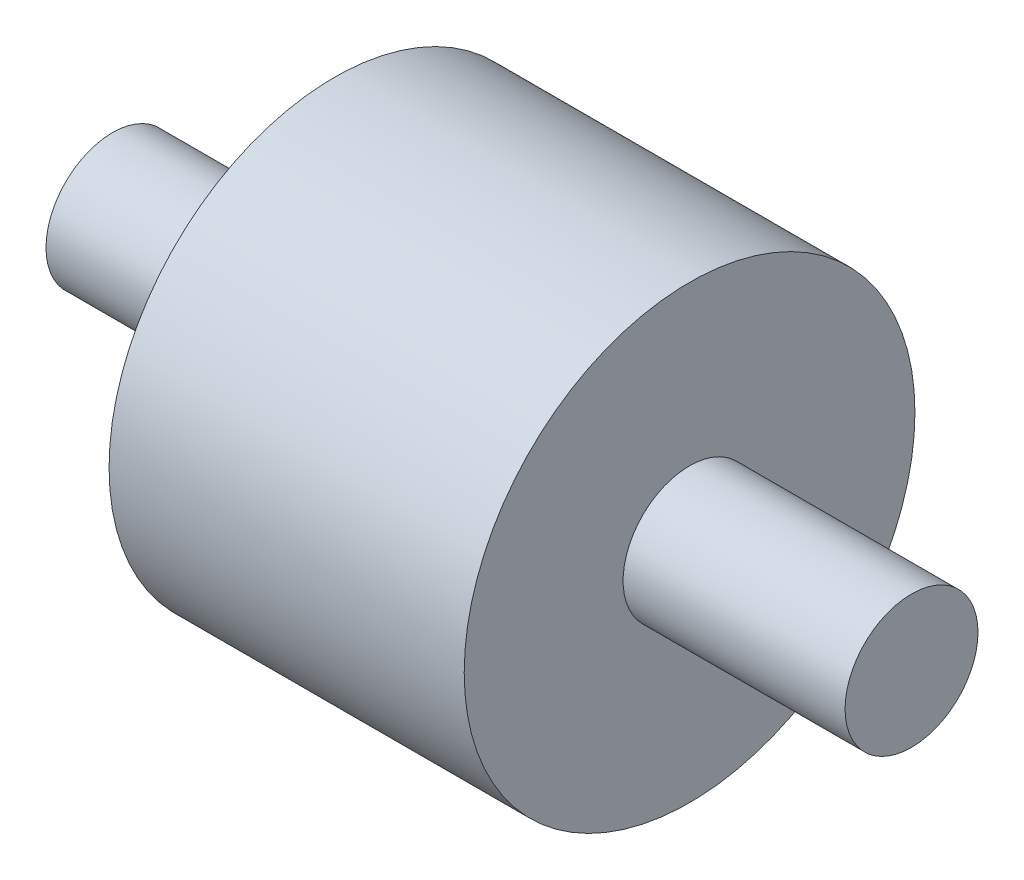
from build123d import *

# Parameters (mm, degrees)
SKETCH1_R                = 25.3837
BOSS_EXTRUDE1_DEPTH      = 40
SKETCH2_R                = 7.485924983
BOSS_EXTRUDE2_DEPTH      = 25
BOSS_EXTRUDE2_DEPTH_BACK = 65


with BuildPart() as part:
    # Sketch1 → Boss-Extrude1 (new body)
    with BuildSketch(Plane(origin=(0, 0, 0), x_dir=(0, 0, -1), z_dir=(1, 0, 0))):
        Circle(SKETCH1_R)
    extrude(amount=BOSS_EXTRUDE1_DEPTH)

    # Sketch2 → Boss-Extrude2 (add, two sides)
    with BuildSketch(Plane.ZY) as boss_extrude2_sk:
        Circle(SKETCH2_R)
    extrude(amount=BOSS_EXTRUDE2_DEPTH)
    extrude(boss_extrude2_sk.sketch, amount=-BOSS_EXTRUDE2_DEPTH_BACK)


solid = part.part
